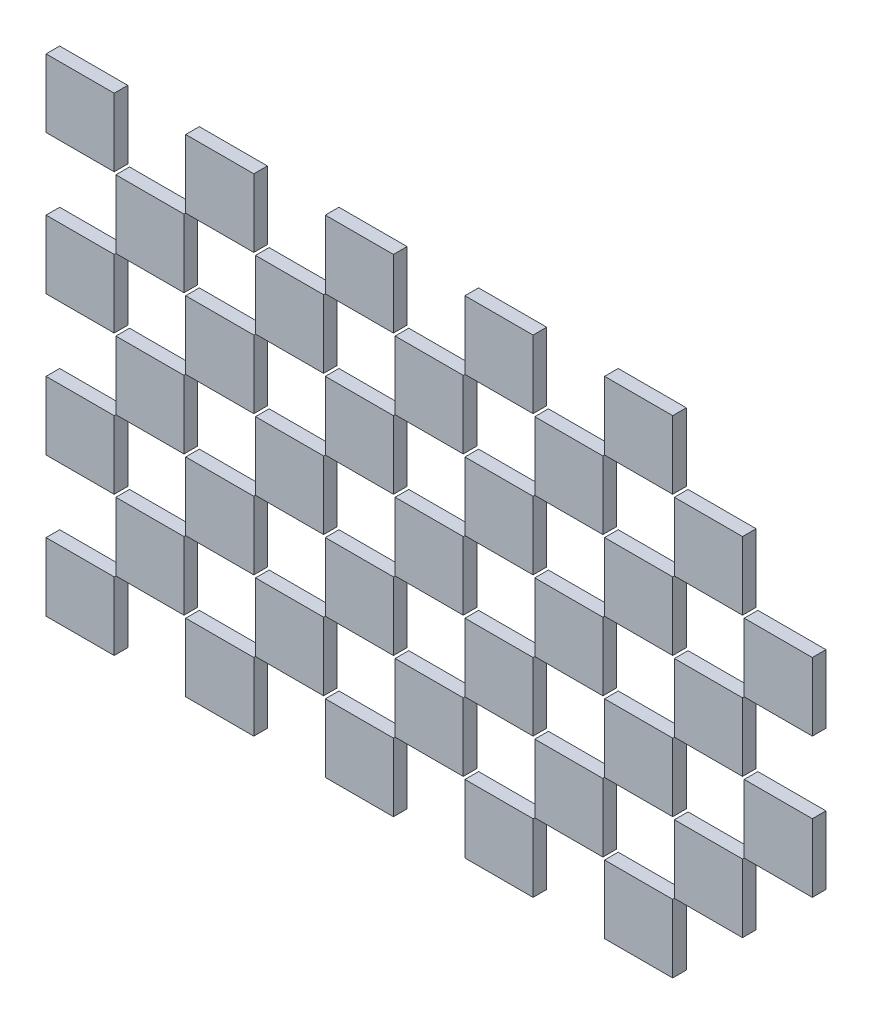
from build123d import *

# Parameters (mm, degrees)
SKETCH_1_W                  = 2
SKETCH_1_H                  = 2
EXTRUDE_1_DEPTH             = 0.4
PATTERN_LINEAR_1_COUNT      = 4
PATTERN_LINEAR_1_PITCH      = 4.1
PATTERN_LINEAR_1_2_COUNT    = 6
PATTERN_LINEAR_1_2_PITCH    = 4.1
SKETCH_2_W                  = 2
SKETCH_2_H                  = 2
EXTRUDE_2_DEPTH             = 0.4
PATTERN_LINEAR_2_COUNT      = 3
PATTERN_LINEAR_2_PITCH      = 4.1
PATTERN_LINEAR_2_COUNT_DIR2 = 5
PATTERN_LINEAR_2_PITCH_DIR2 = 4.1


with BuildPart() as part:
    # 草图1 → 凸台-拉伸1 (new body)
    with BuildSketch(Plane.XY):
        with Locations((-5.705263158, 7.115789474)):
            Rectangle(SKETCH_1_W, SKETCH_1_H)
    extrude(amount=EXTRUDE_1_DEPTH)


with BuildPart() as pattern_linear_1_1:
    # 阵列(线性)1: pattern copy
    add(part.part.moved(Location(Vector(0, 1, 0) * (1 * PATTERN_LINEAR_1_PITCH))))


with BuildPart() as pattern_linear_1_2:
    # 阵列(线性)1: pattern copy
    add(part.part.moved(Location(Vector(0, 1, 0) * (2 * PATTERN_LINEAR_1_PITCH))))


with BuildPart() as pattern_linear_1_3:
    # 阵列(线性)1: pattern copy
    add(part.part.moved(Location(Vector(0, 1, 0) * (3 * PATTERN_LINEAR_1_PITCH))))


with BuildPart() as pattern_linear_1_2_1:
    # Pattern Linear 1 2: pattern copy
    add(part.part.moved(Location(Vector(1, 0, 0) * (1 * PATTERN_LINEAR_1_2_PITCH))))


with BuildPart() as pattern_linear_1_2_2:
    # Pattern Linear 1 2: pattern copy
    add(part.part.moved(Location(Vector(1, 0, 0) * (2 * PATTERN_LINEAR_1_2_PITCH))))


with BuildPart() as pattern_linear_1_2_3:
    # Pattern Linear 1 2: pattern copy
    add(part.part.moved(Location(Vector(1, 0, 0) * (3 * PATTERN_LINEAR_1_2_PITCH))))


with BuildPart() as pattern_linear_1_2_4:
    # Pattern Linear 1 2: pattern copy
    add(part.part.moved(Location(Vector(1, 0, 0) * (4 * PATTERN_LINEAR_1_2_PITCH))))


with BuildPart() as pattern_linear_1_2_5:
    # Pattern Linear 1 2: pattern copy
    add(part.part.moved(Location(Vector(1, 0, 0) * (5 * PATTERN_LINEAR_1_2_PITCH))))


with BuildPart() as pattern_linear_1_2_6:
    # Pattern Linear 1 2: pattern copy
    add(pattern_linear_1_1.part.moved(Location(Vector(1, 0, 0) * (1 * PATTERN_LINEAR_1_2_PITCH))))


with BuildPart() as pattern_linear_1_2_7:
    # Pattern Linear 1 2: pattern copy
    add(pattern_linear_1_1.part.moved(Location(Vector(1, 0, 0) * (2 * PATTERN_LINEAR_1_2_PITCH))))


with BuildPart() as pattern_linear_1_2_8:
    # Pattern Linear 1 2: pattern copy
    add(pattern_linear_1_1.part.moved(Location(Vector(1, 0, 0) * (3 * PATTERN_LINEAR_1_2_PITCH))))


with BuildPart() as pattern_linear_1_2_9:
    # Pattern Linear 1 2: pattern copy
    add(pattern_linear_1_1.part.moved(Location(Vector(1, 0, 0) * (4 * PATTERN_LINEAR_1_2_PITCH))))


with BuildPart() as pattern_linear_1_2_10:
    # Pattern Linear 1 2: pattern copy
    add(pattern_linear_1_1.part.moved(Location(Vector(1, 0, 0) * (5 * PATTERN_LINEAR_1_2_PITCH))))


with BuildPart() as pattern_linear_1_2_11:
    # Pattern Linear 1 2: pattern copy
    add(pattern_linear_1_2.part.moved(Location(Vector(1, 0, 0) * (1 * PATTERN_LINEAR_1_2_PITCH))))


with BuildPart() as pattern_linear_1_2_12:
    # Pattern Linear 1 2: pattern copy
    add(pattern_linear_1_2.part.moved(Location(Vector(1, 0, 0) * (2 * PATTERN_LINEAR_1_2_PITCH))))


with BuildPart() as pattern_linear_1_2_13:
    # Pattern Linear 1 2: pattern copy
    add(pattern_linear_1_2.part.moved(Location(Vector(1, 0, 0) * (3 * PATTERN_LINEAR_1_2_PITCH))))


with BuildPart() as pattern_linear_1_2_14:
    # Pattern Linear 1 2: pattern copy
    add(pattern_linear_1_2.part.moved(Location(Vector(1, 0, 0) * (4 * PATTERN_LINEAR_1_2_PITCH))))


with BuildPart() as pattern_linear_1_2_15:
    # Pattern Linear 1 2: pattern copy
    add(pattern_linear_1_2.part.moved(Location(Vector(1, 0, 0) * (5 * PATTERN_LINEAR_1_2_PITCH))))


with BuildPart() as pattern_linear_1_2_16:
    # Pattern Linear 1 2: pattern copy
    add(pattern_linear_1_3.part.moved(Location(Vector(1, 0, 0) * (1 * PATTERN_LINEAR_1_2_PITCH))))


with BuildPart() as pattern_linear_1_2_17:
    # Pattern Linear 1 2: pattern copy
    add(pattern_linear_1_3.part.moved(Location(Vector(1, 0, 0) * (2 * PATTERN_LINEAR_1_2_PITCH))))


with BuildPart() as pattern_linear_1_2_18:
    # Pattern Linear 1 2: pattern copy
    add(pattern_linear_1_3.part.moved(Location(Vector(1, 0, 0) * (3 * PATTERN_LINEAR_1_2_PITCH))))


with BuildPart() as pattern_linear_1_2_19:
    # Pattern Linear 1 2: pattern copy
    add(pattern_linear_1_3.part.moved(Location(Vector(1, 0, 0) * (4 * PATTERN_LINEAR_1_2_PITCH))))


with BuildPart() as pattern_linear_1_2_20:
    # Pattern Linear 1 2: pattern copy
    add(pattern_linear_1_3.part.moved(Location(Vector(1, 0, 0) * (5 * PATTERN_LINEAR_1_2_PITCH))))


with BuildPart() as body_25:
    # 草图2 → 凸台-拉伸2 (new body)
    with BuildSketch(Plane.XY):
        with Locations((-3.655263158, 9.165789474)):
            Rectangle(SKETCH_2_W, SKETCH_2_H)
    extrude_2 = extrude(amount=EXTRUDE_2_DEPTH)


with BuildPart() as pattern_linear_2_1:
    # 阵列(线性)2: Extrude 2 3 × 5
    with Locations(*[(j * PATTERN_LINEAR_2_PITCH_DIR2, i * PATTERN_LINEAR_2_PITCH, 0) for i in range(PATTERN_LINEAR_2_COUNT) for j in range(PATTERN_LINEAR_2_COUNT_DIR2) if (i, j) != (0, 0)]):
        add(extrude_2)


solid = Compound([part.part, pattern_linear_1_1.part, pattern_linear_1_2.part, pattern_linear_1_3.part, pattern_linear_1_2_1.part, pattern_linear_1_2_2.part, pattern_linear_1_2_3.part, pattern_linear_1_2_4.part, pattern_linear_1_2_6.part, pattern_linear_1_2_7.part, pattern_linear_1_2_8.part, pattern_linear_1_2_9.part, pattern_linear_1_2_10.part, pattern_linear_1_2_11.part, pattern_linear_1_2_12.part, pattern_linear_1_2_13.part, pattern_linear_1_2_14.part, pattern_linear_1_2_15.part, pattern_linear_1_2_16.part, pattern_linear_1_2_17.part, pattern_linear_1_2_18.part, pattern_linear_1_2_19.part, body_25.part, pattern_linear_2_1.part])
